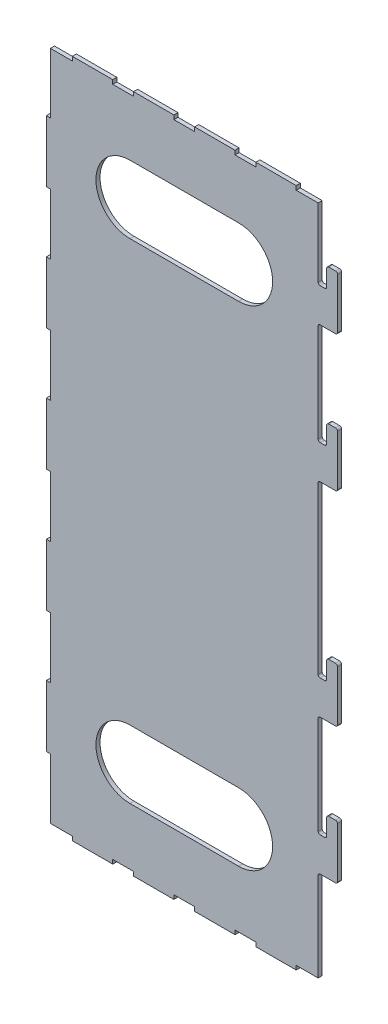
from build123d import *

# Parameters (mm, degrees)
SALIENTE_EXTRUIR1_DEPTH = 3
CORTAR_EXTRUIR1_REACH   = 5
CROQUIS2_W              = 15.3
CROQUIS2_H              = 3
CROQUIS2_W_2            = 16.15
CROQUIS2_W_3            = 3
CROQUIS2_H_2            = 44.7


with BuildPart() as part:
    # Croquis1 → Saliente-Extruir1 (new body)
    with BuildSketch(Plane.XY):
        with BuildLine():
            Line((101.5, 195), (104.8, 195))
            ThreePointArc((104.8, 195), (105.860660172, 195.439339828), (106.3, 196.5))
            Line((106.3, 196.5), (106.3, 208.5))
            ThreePointArc((106.3, 208.5), (106.739339828, 209.560660172), (107.8, 210))
            Line((107.8, 210), (112.8, 210))
            ThreePointArc((112.8, 210), (113.860660172, 209.560660172), (114.3, 208.5))
            Line((114.3, 208.5), (114.3, 171.5))
            ThreePointArc((114.3, 171.5), (113.860660172, 170.439339828), (112.8, 170))
            Line((112.8, 170), (101.5, 170))
            ThreePointArc((101.5, 170), (100.439339828, 169.560660172), (100, 168.5))
            Line((100, 168.5), (100, 96.5))
            ThreePointArc((100, 96.5), (100.439339828, 95.439339828), (101.5, 95))
            Line((101.5, 95), (104.8, 95))
            ThreePointArc((104.8, 95), (105.860660172, 95.439339828), (106.3, 96.5))
            Line((106.3, 96.5), (106.3, 108.5))
            ThreePointArc((106.3, 108.5), (106.739339828, 109.560660172), (107.8, 110))
            Line((107.8, 110), (112.8, 110))
            ThreePointArc((112.8, 110), (113.860660172, 109.560660172), (114.3, 108.5))
            Line((114.3, 108.5), (114.3, 71.5))
            ThreePointArc((114.3, 71.5), (113.860660172, 70.439339828), (112.8, 70))
            Line((112.8, 70), (101.5, 70))
            ThreePointArc((101.5, 70), (100.439339828, 69.560660172), (100, 68.5))
            Line((100, 68.5), (100, -53.5))
            ThreePointArc((100, -53.5), (100.439339828, -54.560660172), (101.5, -55))
            Line((101.5, -55), (104.8, -55))
            ThreePointArc((104.8, -55), (105.860660172, -54.560660172), (106.3, -53.5))
            Line((106.3, -53.5), (106.3, -41.5))
            ThreePointArc((106.3, -41.5), (106.739339828, -40.439339828), (107.8, -40))
            Line((107.8, -40), (112.8, -40))
            ThreePointArc((112.8, -40), (113.860660172, -40.439339828), (114.3, -41.5))
            Line((114.3, -41.5), (114.3, -78.5))
            ThreePointArc((114.3, -78.5), (113.860660172, -79.560660172), (112.8, -80))
            Line((112.8, -80), (101.5, -80))
            ThreePointArc((101.5, -80), (100.439339828, -80.439339828), (100, -81.5))
            Line((100, -81.5), (100, -153.5))
            ThreePointArc((100, -153.5), (100.439339828, -154.560660172), (101.5, -155))
            Line((101.5, -155), (104.8, -155))
            ThreePointArc((104.8, -155), (105.860660172, -154.560660172), (106.3, -153.5))
            Line((106.3, -153.5), (106.3, -141.5))
            ThreePointArc((106.3, -141.5), (106.739339828, -140.439339828), (107.8, -140))
            Line((107.8, -140), (112.8, -140))
            ThreePointArc((112.8, -140), (113.860660172, -140.439339828), (114.3, -141.5))
            Line((114.3, -141.5), (114.3, -178.5))
            ThreePointArc((114.3, -178.5), (113.860660172, -179.560660172), (112.8, -180))
            Line((112.8, -180), (101.5, -180))
            ThreePointArc((101.5, -180), (100.439339828, -180.439339828), (100, -181.5))
            Line((100, -181.5), (100, -250))
            Line((100, -250), (-100, -250))
            Line((-100, -250), (-100, 250))
            Line((-100, 250), (100, 250))
            Line((100, 250), (100, 196.5))
            ThreePointArc((100, 196.5), (100.439339828, 195.439339828), (101.5, 195))
        make_face()
    extrude(amount=SALIENTE_EXTRUIR1_DEPTH)

    # Croquis2 → Cortar-Extruir1 (cut, up to next)
    with BuildSketch(Plane.XY.offset(3), mode=Mode.PRIVATE) as cortar_extruir1_sk1:
        Polygon((-100, -250), (-80.85, -250), (-80.85, -247), (-97, -247), (-97, -202.65), (-100, -202.65), align=None)
    cortar_extruir1_tool1 = extrude(cortar_extruir1_sk1.sketch, amount=-CORTAR_EXTRUIR1_REACH, mode=Mode.PRIVATE) & part.part
    add(cortar_extruir1_tool1.solids().sort_by_distance((-99.489241, -226.325, 3))[0], mode=Mode.SUBTRACT)
    # Croquis2 → Cortar-Extruir1 (cut, up to next)
    with BuildSketch(Plane.XY.offset(3), mode=Mode.PRIVATE) as cortar_extruir1_sk2:
        with Locations((-43.5, -248.5)):
            Rectangle(CROQUIS2_W, CROQUIS2_H)
    cortar_extruir1_tool2 = extrude(cortar_extruir1_sk2.sketch, amount=-CORTAR_EXTRUIR1_REACH, mode=Mode.PRIVATE) & part.part
    add(cortar_extruir1_tool2.solids().sort_by_distance((-43.5, -248.5, 3))[0], mode=Mode.SUBTRACT)
    # Croquis2 → Cortar-Extruir1 (cut, up to next)
    with BuildSketch(Plane.XY.offset(3), mode=Mode.PRIVATE) as cortar_extruir1_sk3:
        with Locations((1.5, -248.5)):
            Rectangle(CROQUIS2_W, CROQUIS2_H)
    cortar_extruir1_tool3 = extrude(cortar_extruir1_sk3.sketch, amount=-CORTAR_EXTRUIR1_REACH, mode=Mode.PRIVATE) & part.part
    add(cortar_extruir1_tool3.solids().sort_by_distance((1.5, -248.5, 3))[0], mode=Mode.SUBTRACT)
    # Croquis2 → Cortar-Extruir1 (cut, up to next)
    with BuildSketch(Plane.XY.offset(3), mode=Mode.PRIVATE) as cortar_extruir1_sk4:
        with Locations((46.5, -248.5)):
            Rectangle(CROQUIS2_W, CROQUIS2_H)
    cortar_extruir1_tool4 = extrude(cortar_extruir1_sk4.sketch, amount=-CORTAR_EXTRUIR1_REACH, mode=Mode.PRIVATE) & part.part
    add(cortar_extruir1_tool4.solids().sort_by_distance((46.5, -248.5, 3))[0], mode=Mode.SUBTRACT)
    # Croquis2 → Cortar-Extruir1 (cut, up to next)
    with BuildSketch(Plane.XY.offset(3), mode=Mode.PRIVATE) as cortar_extruir1_sk5:
        with Locations((91.925, -248.5)):
            Rectangle(CROQUIS2_W_2, CROQUIS2_H)
    cortar_extruir1_tool5 = extrude(cortar_extruir1_sk5.sketch, amount=-CORTAR_EXTRUIR1_REACH, mode=Mode.PRIVATE) & part.part
    add(cortar_extruir1_tool5.solids().sort_by_distance((91.925, -248.5, 3))[0], mode=Mode.SUBTRACT)
    # Croquis2 → Cortar-Extruir1 (cut, up to next)
    with BuildSketch(Plane.XY.offset(3), mode=Mode.PRIVATE) as cortar_extruir1_sk6:
        with Locations((-98.5, -135)):
            Rectangle(CROQUIS2_W_3, CROQUIS2_H_2)
    cortar_extruir1_tool6 = extrude(cortar_extruir1_sk6.sketch, amount=-CORTAR_EXTRUIR1_REACH, mode=Mode.PRIVATE) & part.part
    add(cortar_extruir1_tool6.solids().sort_by_distance((-98.5, -135, 3))[0], mode=Mode.SUBTRACT)
    # Croquis2 → Cortar-Extruir1 (cut, up to next)
    with BuildSketch(Plane.XY.offset(3), mode=Mode.PRIVATE) as cortar_extruir1_sk7:
        with Locations((-98.5, -45)):
            Rectangle(CROQUIS2_W_3, CROQUIS2_H_2)
    cortar_extruir1_tool7 = extrude(cortar_extruir1_sk7.sketch, amount=-CORTAR_EXTRUIR1_REACH, mode=Mode.PRIVATE) & part.part
    add(cortar_extruir1_tool7.solids().sort_by_distance((-98.5, -45, 3))[0], mode=Mode.SUBTRACT)
    # Croquis2 → Cortar-Extruir1 (cut, up to next)
    with BuildSketch(Plane.XY.offset(3), mode=Mode.PRIVATE) as cortar_extruir1_sk8:
        with Locations((-98.5, 45)):
            Rectangle(CROQUIS2_W_3, CROQUIS2_H_2)
    cortar_extruir1_tool8 = extrude(cortar_extruir1_sk8.sketch, amount=-CORTAR_EXTRUIR1_REACH, mode=Mode.PRIVATE) & part.part
    add(cortar_extruir1_tool8.solids().sort_by_distance((-98.5, 45, 3))[0], mode=Mode.SUBTRACT)
    # Croquis2 → Cortar-Extruir1 (cut, up to next)
    with BuildSketch(Plane.XY.offset(3), mode=Mode.PRIVATE) as cortar_extruir1_sk9:
        with Locations((-98.5, 135)):
            Rectangle(CROQUIS2_W_3, CROQUIS2_H_2)
    cortar_extruir1_tool9 = extrude(cortar_extruir1_sk9.sketch, amount=-CORTAR_EXTRUIR1_REACH, mode=Mode.PRIVATE) & part.part
    add(cortar_extruir1_tool9.solids().sort_by_distance((-98.5, 135, 3))[0], mode=Mode.SUBTRACT)
    # Croquis2 → Cortar-Extruir1 (cut, up to next)
    with BuildSketch(Plane.XY.offset(3), mode=Mode.PRIVATE) as cortar_extruir1_sk10:
        Polygon((-80.85, 247), (-80.85, 250), (-100, 250), (-100, 202.65), (-97, 202.65), (-97, 247), align=None)
    cortar_extruir1_tool10 = extrude(cortar_extruir1_sk10.sketch, amount=-CORTAR_EXTRUIR1_REACH, mode=Mode.PRIVATE) & part.part
    add(cortar_extruir1_tool10.solids().sort_by_distance((-81.360759, 248.5, 3))[0], mode=Mode.SUBTRACT)
    # Croquis2 → Cortar-Extruir1 (cut, up to next)
    with BuildSketch(Plane.XY.offset(3), mode=Mode.PRIVATE) as cortar_extruir1_sk11:
        with Locations((-43.5, 248.5)):
            Rectangle(CROQUIS2_W, CROQUIS2_H)
    cortar_extruir1_tool11 = extrude(cortar_extruir1_sk11.sketch, amount=-CORTAR_EXTRUIR1_REACH, mode=Mode.PRIVATE) & part.part
    add(cortar_extruir1_tool11.solids().sort_by_distance((-43.5, 248.5, 3))[0], mode=Mode.SUBTRACT)
    # Croquis2 → Cortar-Extruir1 (cut, up to next)
    with BuildSketch(Plane.XY.offset(3), mode=Mode.PRIVATE) as cortar_extruir1_sk12:
        with BuildLine():
            ThreePointArc((41.5, 155), (59.17766953, 162.32233047), (66.5, 180))
            ThreePointArc((66.5, 180), (59.17766953, 197.67766953), (41.5, 205))
            Line((41.5, 205), (-38.5, 205))
            ThreePointArc((-38.5, 205), (-63.5, 180), (-38.5, 155))
            Line((-38.5, 155), (41.5, 155))
        make_face()
    cortar_extruir1_tool12 = extrude(cortar_extruir1_sk12.sketch, amount=-CORTAR_EXTRUIR1_REACH, mode=Mode.PRIVATE) & part.part
    add(cortar_extruir1_tool12.solids().sort_by_distance((1.5, 180, 3))[0], mode=Mode.SUBTRACT)
    # Croquis2 → Cortar-Extruir1 (cut, up to next)
    with BuildSketch(Plane.XY.offset(3), mode=Mode.PRIVATE) as cortar_extruir1_sk13:
        with Locations((46.5, 248.5)):
            Rectangle(CROQUIS2_W, CROQUIS2_H)
    cortar_extruir1_tool13 = extrude(cortar_extruir1_sk13.sketch, amount=-CORTAR_EXTRUIR1_REACH, mode=Mode.PRIVATE) & part.part
    add(cortar_extruir1_tool13.solids().sort_by_distance((46.5, 248.5, 3))[0], mode=Mode.SUBTRACT)
    # Croquis2 → Cortar-Extruir1 (cut, up to next)
    with BuildSketch(Plane.XY.offset(3), mode=Mode.PRIVATE) as cortar_extruir1_sk14:
        with Locations((1.5, 248.5)):
            Rectangle(CROQUIS2_W, CROQUIS2_H)
    cortar_extruir1_tool14 = extrude(cortar_extruir1_sk14.sketch, amount=-CORTAR_EXTRUIR1_REACH, mode=Mode.PRIVATE) & part.part
    add(cortar_extruir1_tool14.solids().sort_by_distance((1.5, 248.5, 3))[0], mode=Mode.SUBTRACT)
    # Croquis2 → Cortar-Extruir1 (cut, up to next)
    with BuildSketch(Plane.XY.offset(3), mode=Mode.PRIVATE) as cortar_extruir1_sk15:
        with Locations((91.925, 248.5)):
            Rectangle(CROQUIS2_W_2, CROQUIS2_H)
    cortar_extruir1_tool15 = extrude(cortar_extruir1_sk15.sketch, amount=-CORTAR_EXTRUIR1_REACH, mode=Mode.PRIVATE) & part.part
    add(cortar_extruir1_tool15.solids().sort_by_distance((91.925, 248.5, 3))[0], mode=Mode.SUBTRACT)
    # Croquis2 → Cortar-Extruir1 (cut, up to next)
    with BuildSketch(Plane.XY.offset(3), mode=Mode.PRIVATE) as cortar_extruir1_sk16:
        with BuildLine():
            ThreePointArc((41.5, -205), (59.17766953, -197.67766953), (66.5, -180))
            ThreePointArc((66.5, -180), (59.17766953, -162.32233047), (41.5, -155))
            Line((41.5, -155), (-38.5, -155))
            ThreePointArc((-38.5, -155), (-63.5, -180), (-38.5, -205))
            Line((-38.5, -205), (41.5, -205))
        make_face()
    cortar_extruir1_tool16 = extrude(cortar_extruir1_sk16.sketch, amount=-CORTAR_EXTRUIR1_REACH, mode=Mode.PRIVATE) & part.part
    add(cortar_extruir1_tool16.solids().sort_by_distance((1.5, -180, 3))[0], mode=Mode.SUBTRACT)


solid = part.part
